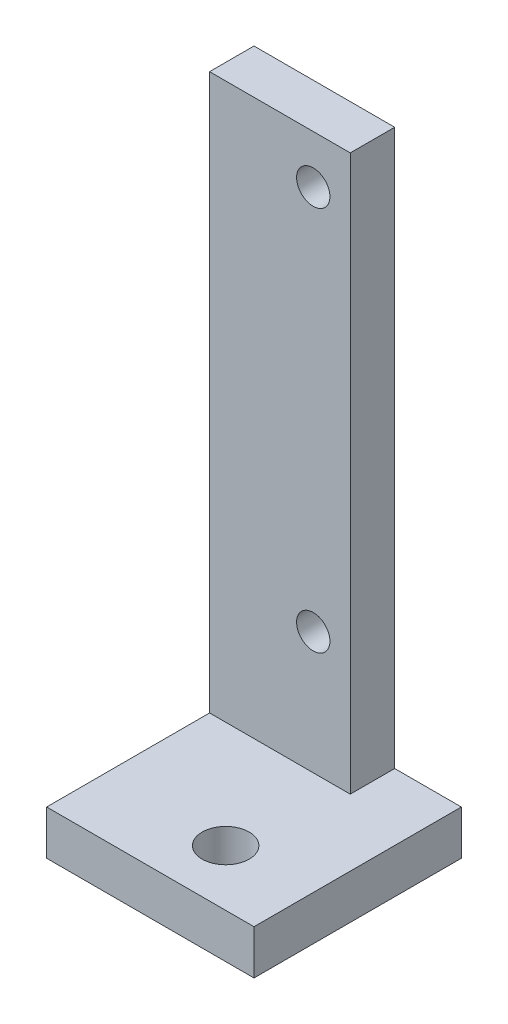
from build123d import *

# Parameters (mm, degrees)
SKETCH1_W           = 10
SKETCH1_H           = 10
SKETCH1_H_2         = 65
SKETCH1_R           = 2.25
BOSS_EXTRUDE1_DEPTH = 6
SKETCH2_W           = 28
SKETCH2_H           = 28
SKETCH2_R           = 3.175
BOSS_EXTRUDE2_DEPTH = 6
SKETCH3_W           = 6
SKETCH3_H           = 75
BOSS_EXTRUDE3_DEPTH = 9


with BuildPart() as part:
    # Sketch1 → Boss-Extrude1 (new body)
    with BuildSketch(Plane.XY):
        with Locations((0, -37.5)):
            Rectangle(SKETCH1_W, SKETCH1_H)
        Rectangle(SKETCH1_W, SKETCH1_H_2)
        with Locations((0, 26)):
            Circle(SKETCH1_R, mode=Mode.SUBTRACT)
        with Locations((0, -26)):
            Circle(SKETCH1_R, mode=Mode.SUBTRACT)
    extrude(amount=BOSS_EXTRUDE1_DEPTH)



with BuildPart() as body_2:
    # Sketch2 → Boss-Extrude2 (new body)
    with BuildSketch(Plane.XZ.offset(42.5)):
        with Locations((0, 14)):
            Rectangle(SKETCH2_W, SKETCH2_H)
        with Locations((2.6, 20.429948245)):
            Circle(SKETCH2_R, mode=Mode.SUBTRACT)
    extrude(amount=BOSS_EXTRUDE2_DEPTH)


with BuildPart() as part_1:
    add(part.part)

    add(body_2.part)  # Boss-Extrude3 merges body 2
    # Sketch3 → Boss-Extrude3 (add)
    with BuildSketch(Plane.ZY.offset(5)):
        with Locations((3, -5)):
            Rectangle(SKETCH3_W, SKETCH3_H)
    extrude(amount=BOSS_EXTRUDE3_DEPTH)


solid = part_1.part
